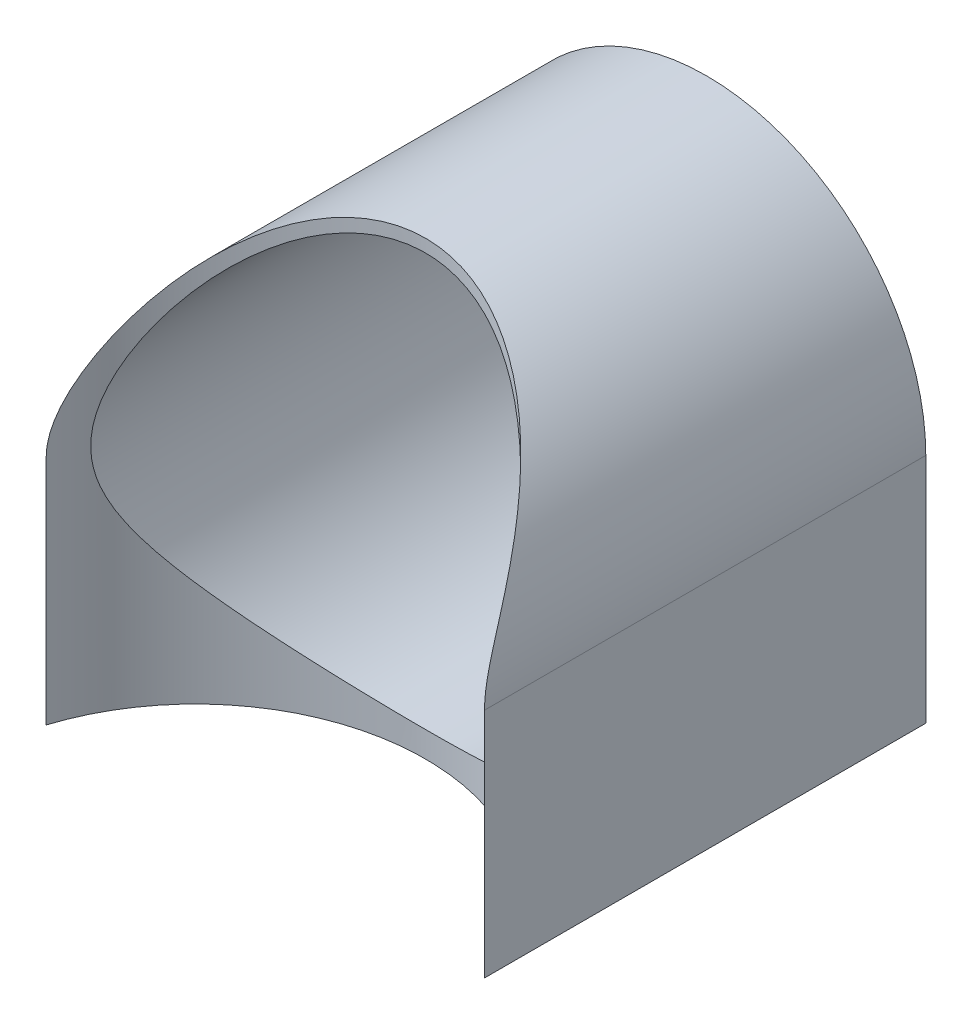
from build123d import *

# Parameters (mm, degrees)
SKETCH1_R           = 17.15
SKETCH1_R_2         = 16.15
BOSS_EXTRUDE1_DEPTH = 40
BOSS_EXTRUDE2_DEPTH = 40
SKETCH2_R           = 18
CUT_EXTRUDE1_DEPTH  = 369.15


with BuildPart() as part:
    # Sketch1 → Boss-Extrude1 (new body)
    with BuildSketch(Plane.XY):
        with Locations((0, 200)):
            Circle(SKETCH1_R)
        with Locations((0, 200)):
            Circle(SKETCH1_R_2, mode=Mode.SUBTRACT)
    extrude(amount=-BOSS_EXTRUDE1_DEPTH)

    # Sketch3 → Boss-Extrude2 (add)
    with BuildSketch(Plane(origin=(0, 0, -40), x_dir=(-1, 0, 0), z_dir=(0, 0, -1))):
        Polygon((17.15, 182.85), (17.15, 181.85), (-17.15, 181.85), (-17.15, 182.85), (0, 182.85), align=None)
        with BuildLine():
            Line((17.15, 182.85), (17.15, 200))
            ThreePointArc((17.15, 200), (12.126881297, 187.873118703), (0, 182.85))
            Line((0, 182.85), (17.15, 182.85))
        make_face()
        with BuildLine():
            ThreePointArc((0, 182.85), (-12.126881297, 187.873118703), (-17.15, 200))
            Line((-17.15, 200), (-17.15, 182.85))
            Line((-17.15, 182.85), (0, 182.85))
        make_face()
    extrude(amount=-BOSS_EXTRUDE2_DEPTH)

    # Sketch2 → Cut-Extrude1 (cut, through all)
    with BuildSketch(Plane(origin=(0, 550, 0), x_dir=(1, 0, 0), z_dir=(0, 1, 0))):
        Circle(SKETCH2_R)
    extrude(amount=-CUT_EXTRUDE1_DEPTH, mode=Mode.SUBTRACT)


solid = part.part
